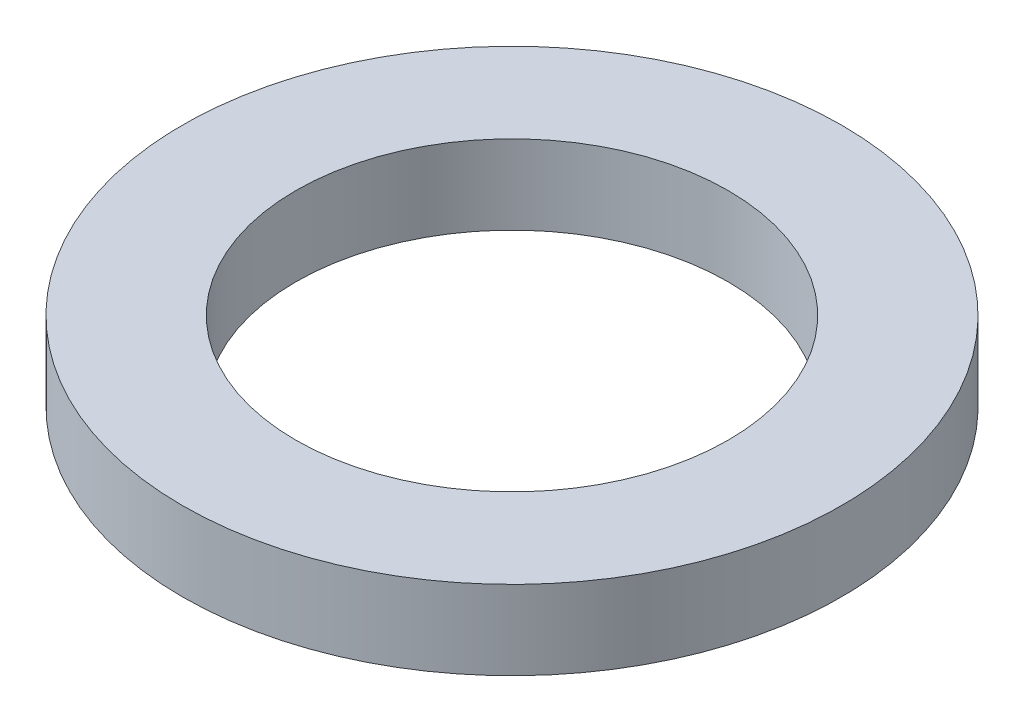
from build123d import *

# Parameters (mm, degrees)
SKETCH1_R           = 25
BOSS_EXTRUDE1_DEPTH = 6
SKETCH2_R           = 16.4
CUT_EXTRUDE1_DEPTH  = 7


with BuildPart() as part:
    # Sketch1 → Boss-Extrude1 (new body)
    with BuildSketch(Plane(origin=(0, 0, 0), x_dir=(1, 0, 0), z_dir=(0, 1, 0))):
        Circle(SKETCH1_R)
    extrude(amount=BOSS_EXTRUDE1_DEPTH)

    # Sketch2 → Cut-Extrude1 (cut, through all)
    with BuildSketch(Plane(origin=(0, 6, 0), x_dir=(1, 0, 0), z_dir=(0, 1, 0))):
        Circle(SKETCH2_R)
    extrude(amount=-CUT_EXTRUDE1_DEPTH, mode=Mode.SUBTRACT)


solid = part.part
